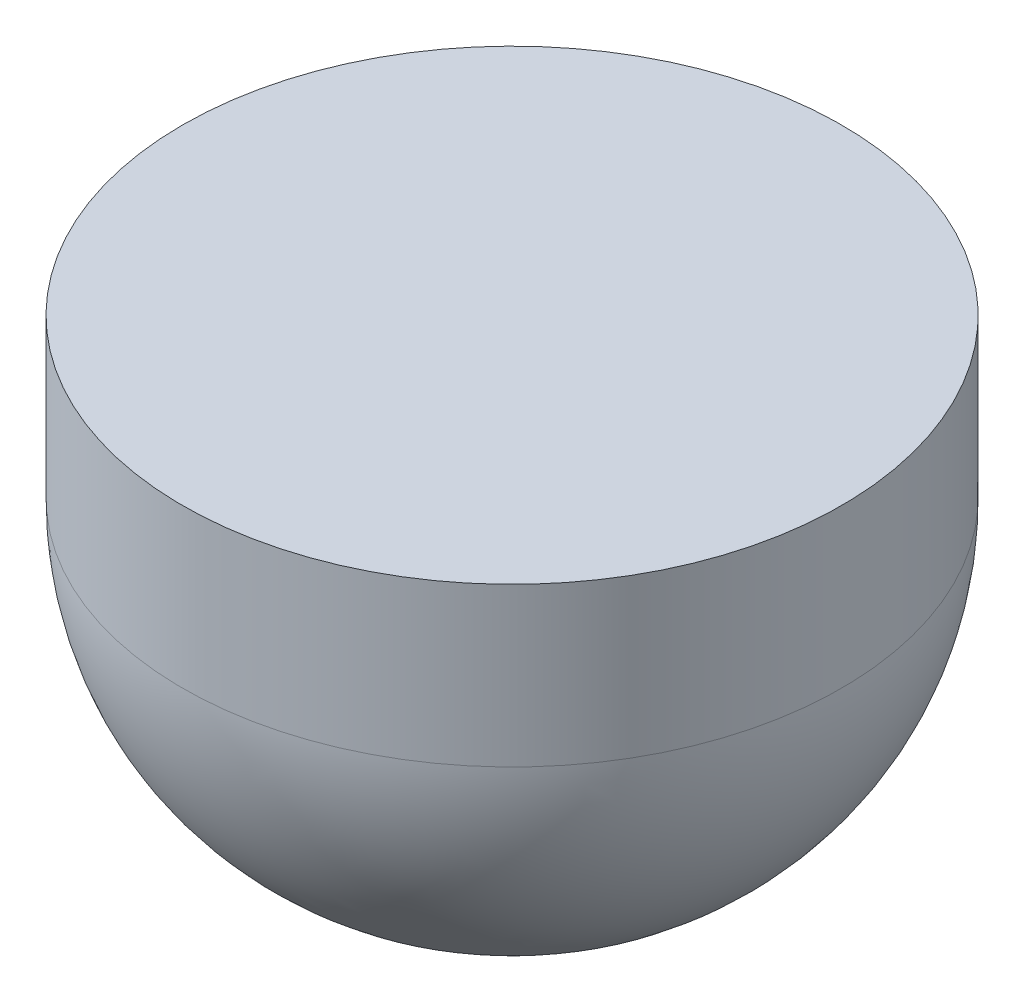
from build123d import *


with BuildPart() as part:
    # Sketch2 → Revolve1 (revolve)
    with BuildSketch(Plane.XY):
        with BuildLine():
            Line((-12.5, 0), (0, 0))
            Line((0, 0), (0, -18))
            Line((0, -18), (-0.5, -18))
            ThreePointArc((-0.5, -18), (-8.985281374, -14.485281374), (-12.5, -6))
            Line((-12.5, -6), (-12.5, 0))
        make_face()
    revolve(axis=Axis((0, 0, 0), (0, -1, 0)))


solid = part.part
